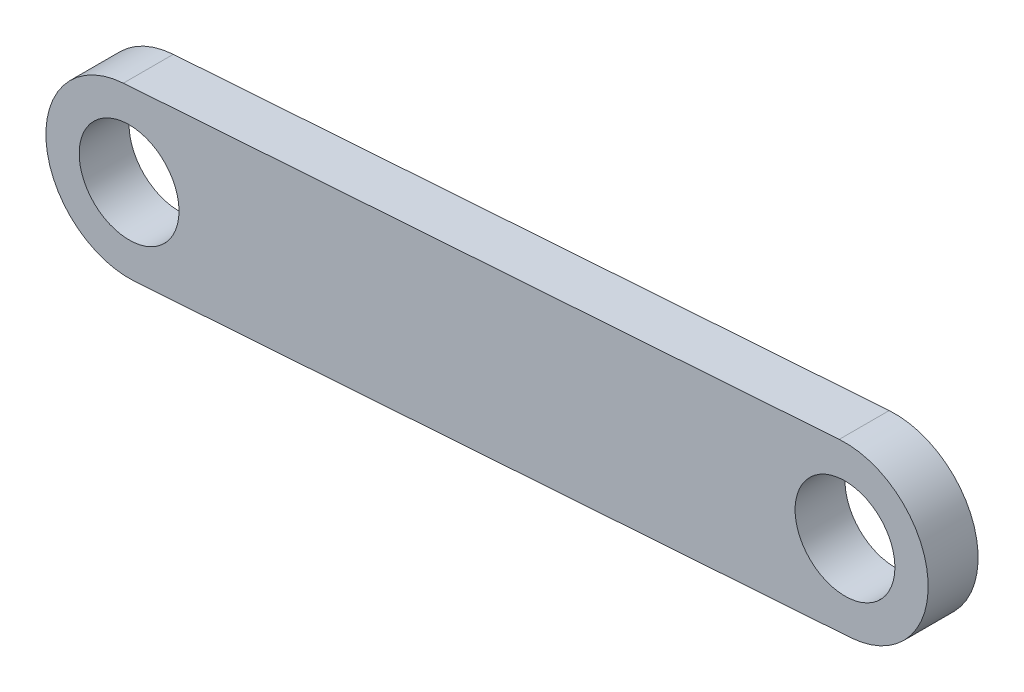
from build123d import *

# Parameters (mm, degrees)
SKETCH2_R           = 7.62
BOSS_EXTRUDE1_DEPTH = 7.62


with BuildPart() as part:
    # Sketch2 → Boss-Extrude1 (new body)
    with BuildSketch(Plane.XY):
        with BuildLine():
            Line((-0.875326504, 12.669798874), (108.401688786, 20.219489971))
            ThreePointArc((108.401688786, 20.219489971), (121.946814164, 8.425017601), (110.152341794, -5.120107777))
            Line((110.152341794, -5.120107777), (0.875326504, -12.669798874))
            ThreePointArc((0.875326504, -12.669798874), (-12.669798874, -0.875326504), (-0.875326504, 12.669798874))
        make_face()
        Circle(SKETCH2_R, mode=Mode.SUBTRACT)
        with Locations((109.27701529, 7.549691097)):
            Circle(SKETCH2_R, mode=Mode.SUBTRACT)
    extrude(amount=BOSS_EXTRUDE1_DEPTH)


solid = part.part
